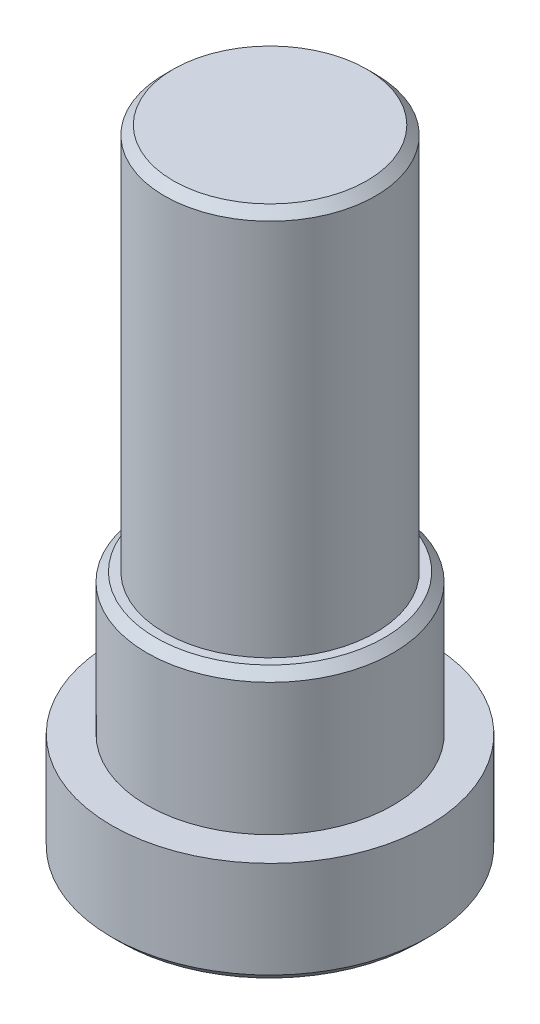
from build123d import *

# Parameters (mm, degrees)
CUT_EXTRUDE1_DEPTH = 1
CHAMFER1_SIZE      = 0.125


with BuildPart() as part:
    # Sketch1 → Revolve1 (revolve)
    with BuildSketch(Plane.XY):
        Polygon((0, 0), (0, 9), (1.5, 9), (1.5, 3.5), (1.75, 3.5), (1.75, 1.5), (2.25, 1.5), (2.25, 0), align=None)
    revolve(axis=Axis((0, 0, 0), (0, -1, 0)))

    # Sketch2 → Cut-Extrude1 (cut)
    with BuildSketch(Plane.XZ):
        Polygon((1.154700538, 0), (0.577350269, 1), (-0.577350269, 1), (-1.154700538, 0), (-0.577350269, -1), (0.577350269, -1), align=None)
    extrude(amount=-CUT_EXTRUDE1_DEPTH, mode=Mode.SUBTRACT)

    # Chamfer1
    chamfer1_edges = [part.edges().sort_by_distance(p)[0] for p in [
        (-2.25, 0, 0),
        (-1.75, 3.5, 0),
        (-1.5, 9, 0),
    ]]
    chamfer(chamfer1_edges, length=CHAMFER1_SIZE)


solid = part.part
